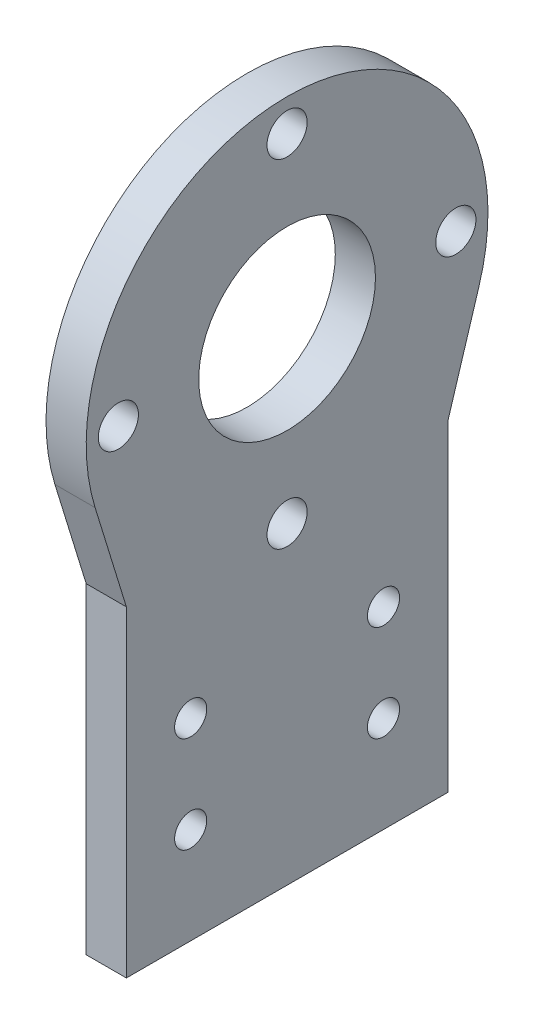
from build123d import *

# Parameters (mm, degrees)
CROQUIS1_R              = 2
CROQUIS1_R_2            = 2.5
CROQUIS1_R_3            = 11
SALIENTE_EXTRUIR1_DEPTH = 5


with BuildPart() as part:
    # Croquis1 → Saliente-Extruir1 (new body)
    with BuildSketch(Plane(origin=(0, 0, 0), x_dir=(0, 0, -1), z_dir=(1, 0, 0))):
        with BuildLine():
            ThreePointArc((43.892972847, 52.642972847), (20, 85), (-3.892972847, 52.642972847))
            Line((-3.892972847, 52.642972847), (0, 40))
            Line((0, 40), (0, 0))
            Line((0, 0), (40, 0))
            Line((40, 0), (40, 40))
            Line((40, 40), (43.892972847, 52.642972847))
        make_face()
        with Locations((8, 12)):
            Circle(CROQUIS1_R, mode=Mode.SUBTRACT)
        with Locations((8, 24)):
            Circle(CROQUIS1_R, mode=Mode.SUBTRACT)
        with Locations((20, 39)):
            Circle(CROQUIS1_R_2, mode=Mode.SUBTRACT)
        with Locations((32, 12)):
            Circle(CROQUIS1_R, mode=Mode.SUBTRACT)
        with Locations((32, 24)):
            Circle(CROQUIS1_R, mode=Mode.SUBTRACT)
        with Locations((-1, 60)):
            Circle(CROQUIS1_R_2, mode=Mode.SUBTRACT)
        with Locations((20, 60)):
            Circle(CROQUIS1_R_3, mode=Mode.SUBTRACT)
        with Locations((20, 81)):
            Circle(CROQUIS1_R_2, mode=Mode.SUBTRACT)
        with Locations((41, 60)):
            Circle(CROQUIS1_R_2, mode=Mode.SUBTRACT)
    extrude(amount=SALIENTE_EXTRUIR1_DEPTH)


solid = part.part
